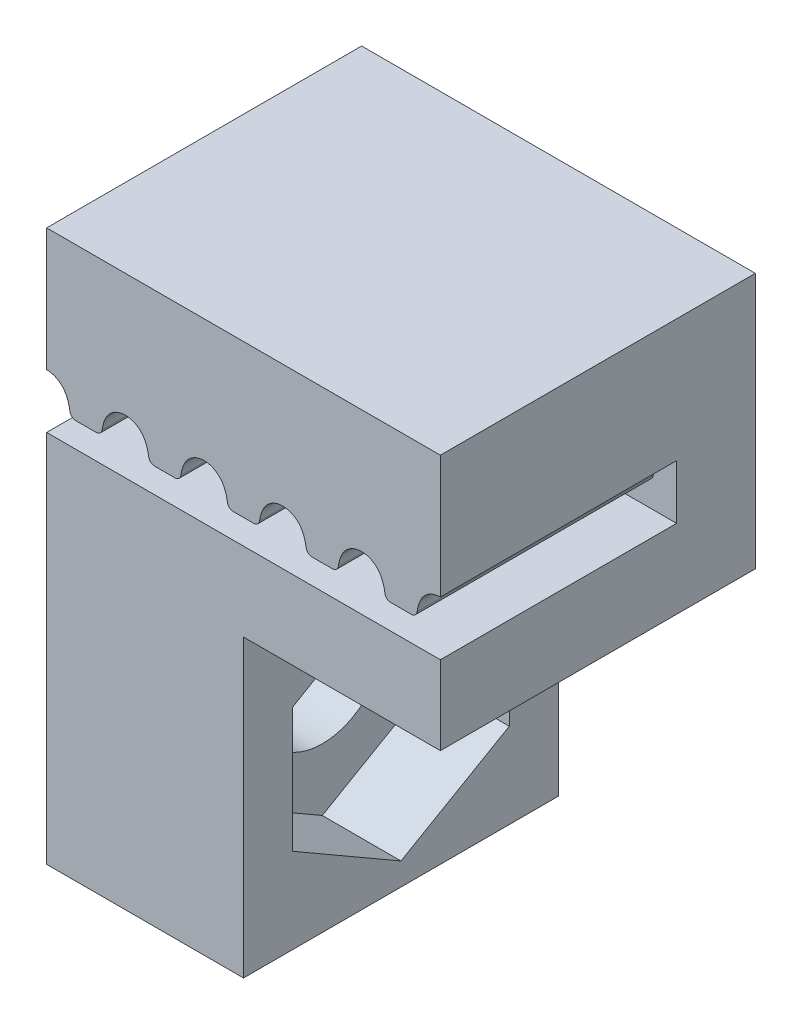
from build123d import *

# Parameters (mm, degrees)
SKETCH3_W           = 10
SKETCH3_H           = 6.5
BOSS_EXTRUDE2_DEPTH = 8
CUT_EXTRUDE1_START  = 2
CUT_EXTRUDE1_DEPTH  = 6
LPATTERN2_COUNT     = 7
LPATTERN2_PITCH     = 2
SKETCH4_W           = 8
SKETCH4_H           = 7.5
BOSS_EXTRUDE3_DEPTH = 5
CUT_EXTRUDE2_START  = -3
CUT_EXTRUDE2_DEPTH  = 2
SKETCH6_R           = 1.6
CUT_EXTRUDE3_DEPTH  = 10


with BuildPart() as part:
    # Sketch3 → Boss-Extrude2 (new body)
    with BuildSketch(Plane.XY):
        with Locations((5, 1.25)):
            Rectangle(SKETCH3_W, SKETCH3_H)
    extrude(amount=BOSS_EXTRUDE2_DEPTH)

    # Sketch1 → Cut-Extrude1 (cut)
    with BuildSketch(Plane.XY.offset(CUT_EXTRUDE1_START)):
        with BuildLine():
            Line((0.740175425, 0.63), (1.259824575, 0.63))
            ThreePointArc((1.259824575, 0.63), (1.358731646, 0.667228588), (1.408543109, 0.760434783))
            ThreePointArc((1.408543109, 0.760434783), (1.442388286, 0.918062154), (1.501123596, 1.068202247))
            ThreePointArc((1.501123596, 1.068202247), (1.705850588, 1.295639059), (2, 1.38))
            Line((2, 1.38), (2, 0))
            Line((2, 0), (0, 0))
            Line((0, 0), (0, 1.38))
            ThreePointArc((0, 1.38), (0.294149412, 1.295639059), (0.498876404, 1.068202247))
            ThreePointArc((0.498876404, 1.068202247), (0.557611714, 0.918062154), (0.591456891, 0.760434783))
            ThreePointArc((0.591456891, 0.760434783), (0.641268354, 0.667228588), (0.740175425, 0.63))
        make_face()
    cut_extrude1 = extrude(amount=CUT_EXTRUDE1_DEPTH, mode=Mode.SUBTRACT)

    # LPattern2: Cut-Extrude1 ×7
    with Locations(*[(i * LPATTERN2_PITCH, 0, 0) for i in range(1, LPATTERN2_COUNT)]):
        add(cut_extrude1, mode=Mode.SUBTRACT)

    # Sketch4 → Boss-Extrude3 (add)
    with BuildSketch(Plane.ZY):
        with Locations((4, -5.75)):
            Rectangle(SKETCH4_W, SKETCH4_H)
    extrude(amount=-BOSS_EXTRUDE3_DEPTH)

    # Sketch5 → Cut-Extrude2 (cut)
    with BuildSketch(Plane.ZY.offset(CUT_EXTRUDE2_START)):
        Polygon((1.25, -4.16228676), (1.25, -7.33771324), (4, -8.925426481), (6.75, -7.33771324), (6.75, -4.16228676), (4, -2.574573519), align=None)
    extrude(amount=-CUT_EXTRUDE2_DEPTH, mode=Mode.SUBTRACT)

    # Sketch6 → Cut-Extrude3 (cut)
    with BuildSketch(Plane.ZY.offset(-3)):
        with Locations((4, -5.75)):
            Circle(SKETCH6_R)
    extrude(amount=CUT_EXTRUDE3_DEPTH, mode=Mode.SUBTRACT)


solid = part.part
